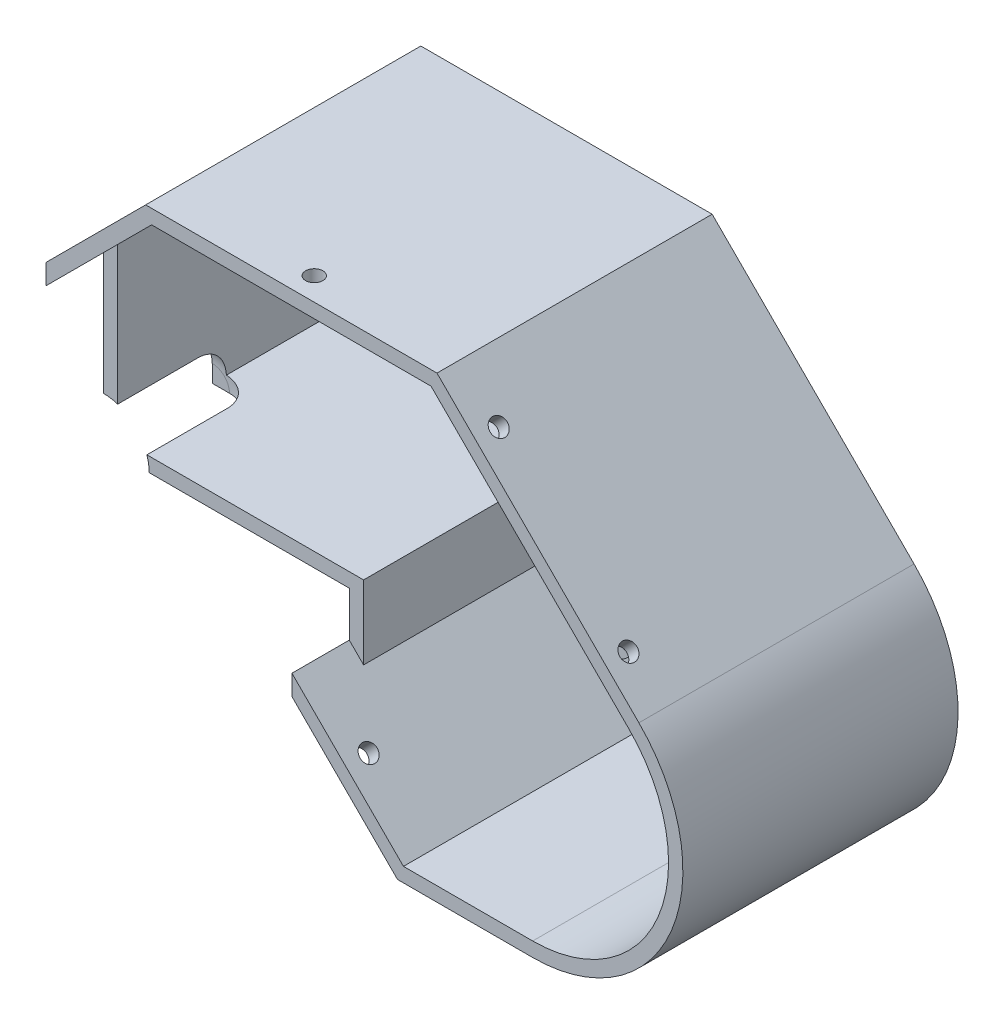
from build123d import *

# Parameters (mm, degrees)
RESSALTO_EXTRUS_O1_DEPTH = 48
ESBO_O12_R               = 1.5
CORTE_EXTRUS_O10_DEPTH   = 10
ESBO_O13_R               = 1.5
CORTE_EXTRUS_O11_DEPTH   = 10
ESBO_O14_R               = 1.5
CORTE_EXTRUS_O12_DEPTH   = 10
ESBO_O15_R               = 1.5
CORTE_EXTRUS_O13_DEPTH   = 10
CORTE_EXTRUS_O14_DEPTH   = 10
ESBO_O17_R               = 4
ESBO_O17_W               = 2.8
ESBO_O17_H               = 2.8
RESSALTO_EXTRUS_O2_DEPTH = 4
CORTE_EXTRUS_O15_DEPTH   = 10


with BuildPart() as part:
    # Model → Ressalto-extrusão1 (new body)
    with BuildSketch(Plane.XY):
        with BuildLine():
            Line((-0.7, 0), (39, 0))
            Line((39, 0), (39.7, 0))
            Line((39.7, 0), (39.7, -11.380317396))
            Line((39.7, -11.380317396), (50.182424304, -21.8627417))
            Line((50.182424304, -21.8627417), (58.119682605, -29.8))
            Line((58.119682605, -29.8), (81.7, -29.8))
            ThreePointArc((81.7, -29.8), (105.905643752, -13.626305928), (100.226197667, 14.926197667))
            Line((100.226197667, 14.926197667), (65.00338056, 50.149014774))
            Line((65.00338056, 50.149014774), (50.111140335, 50.149014774))
            Line((50.111140335, 50.149014774), (14.181595121, 50.149014774))
            Line((14.181595121, 50.149014774), (-3.2, 32.767419653))
            Line((-3.2, 32.767419653), (-3.2, 5))
            Line((-3.2, 5), (-3.2, 0))
            Line((-3.2, 0), (-0.7, 0))
        make_face()
        with BuildLine():
            Line((-0.7, 2.5), (39, 2.5))
            Line((39, 2.5), (39.7, 2.5))
            Line((39.7, 2.5), (42.2, 2.5))
            Line((42.2, 2.5), (42.2, -10.34478349))
            Line((42.2, -10.34478349), (51.950191257, -20.094974747))
            Line((51.950191257, -20.094974747), (59.15521651, -27.3))
            Line((59.15521651, -27.3), (81.7, -27.3))
            ThreePointArc((81.7, -27.3), (103.595944921, -12.669597347), (98.458430714, 13.158430714))
            Line((98.458430714, 13.158430714), (63.967846654, 47.649014774))
            Line((63.967846654, 47.649014774), (50.111140335, 47.649014774))
            Line((50.111140335, 47.649014774), (15.217129027, 47.649014774))
            Line((15.217129027, 47.649014774), (-0.7, 31.731885747))
            Line((-0.7, 31.731885747), (-0.7, 2.5))
        make_face(mode=Mode.SUBTRACT)
    extrude(amount=RESSALTO_EXTRUS_O1_DEPTH)

    # Esboço12 → Corte-extrusão10 (cut)
    with BuildSketch(Plane(origin=(57.576197667, 57.576197667, 0), x_dir=(0, 0, -1), z_dir=(0.707106781, 0.707106781, 0))):
        with Locations((-44, -20.072657306)):
            Circle(ESBO_O12_R)
        with Locations((-44, -52.072657306)):
            Circle(ESBO_O12_R)
    extrude(amount=-CORTE_EXTRUS_O10_DEPTH, mode=Mode.SUBTRACT)

    # Esboço13 → Corte-extrusão11 (cut)
    with BuildSketch(Plane(origin=(0, 50.149014774, 0), x_dir=(1, 0, 0), z_dir=(0, 1, 0))):
        with Locations((39.59248784, -44)):
            Circle(ESBO_O13_R)
    extrude(amount=-CORTE_EXTRUS_O11_DEPTH, mode=Mode.SUBTRACT)

    # Esboço14 → Corte-extrusão12 (cut)
    with BuildSketch(Plane.ZY.offset(3.2)):
        with Locations((44, 23.701037279)):
            Circle(ESBO_O14_R)
        with Locations((44, 7.740898975)):
            Circle(ESBO_O14_R)
    extrude(amount=-CORTE_EXTRUS_O12_DEPTH, mode=Mode.SUBTRACT)

    # Esboço15 → Corte-extrusão13 (cut)
    with BuildSketch(Plane(origin=(14.159841302, 14.159841302, 0), x_dir=(0, 0, 1), z_dir=(-0.707106781, -0.707106781, 0))):
        with Locations((44, -46.881179593)):
            Circle(ESBO_O15_R)
    extrude(amount=-CORTE_EXTRUS_O13_DEPTH, mode=Mode.SUBTRACT)

    # Esboço16 → Corte-extrusão14 (cut)
    with BuildSketch(Plane.XY.offset(48)):
        Polygon((39.7, 0), (39.7, -7.84478349), (42.2, -10.34478349), (42.2, 2.5), (-0.7, 2.5), (-0.7, 0), align=None)
    extrude(amount=-CORTE_EXTRUS_O14_DEPTH, mode=Mode.SUBTRACT)

    # Esboço17 → Ressalto-extrusão2 (add)
    with BuildSketch(Plane(origin=(0, 0, 0), x_dir=(-1, 0, 0), z_dir=(0, 0, -1))):
        with Locations((-91.568699638, 17.926841447)):
            Circle(ESBO_O17_R)
        with Locations((-91.568699638, 17.926841447)):
            Rectangle(ESBO_O17_W, ESBO_O17_H, mode=Mode.SUBTRACT)
        with Locations((-68.47265349, 41.022887595)):
            Circle(ESBO_O17_R)
        with Locations((-68.47265349, 41.022887595)):
            Rectangle(ESBO_O17_W, ESBO_O17_H, mode=Mode.SUBTRACT)
        with Locations((-39.59248784, 46.149014774)):
            Circle(ESBO_O17_R)
        with Locations((-39.59248784, 46.149014774)):
            Rectangle(ESBO_O17_W, ESBO_O17_H, mode=Mode.SUBTRACT)
        with Locations((-0.8, 24.383709827)):
            Circle(ESBO_O17_R)
        with Locations((-0.8, 24.383709827)):
            Rectangle(ESBO_O17_W, ESBO_O17_H, mode=Mode.SUBTRACT)
        with Locations((-0.8, 8.383709827)):
            Circle(ESBO_O17_R)
        with Locations((-0.8, 8.383709827)):
            Rectangle(ESBO_O17_W, ESBO_O17_H, mode=Mode.SUBTRACT)
        with Locations((-51.388268427, -17.411731573)):
            Circle(ESBO_O17_R)
        with Locations((-51.388268427, -17.411731573)):
            Rectangle(ESBO_O17_W, ESBO_O17_H, mode=Mode.SUBTRACT)
    extrude(amount=-RESSALTO_EXTRUS_O2_DEPTH)

    # Esboço18 → Corte-extrusão15 (cut)
    with BuildSketch(Plane.XY.offset(48)):
        Polygon((-0.7, 31.731885747), (-32.431885747, 0), (-0.7, 0), align=None)
    extrude(amount=-CORTE_EXTRUS_O15_DEPTH, mode=Mode.SUBTRACT)

    # Esboço19 → Corte-Revolução1 (revolve, cut)
    with BuildSketch(Plane.ZY.offset(3.2)):
        with BuildLine():
            Line((19, 0), (29, 0))
            Line((29, 0), (38.25689259, 0))
            Line((38.25689259, 0), (38.25689259, 8))
            Line((38.25689259, 8), (24, 8))
            ThreePointArc((24, 8), (20.464466094, 6.535533906), (19, 3))
            Line((19, 3), (19, 0))
        make_face()
    revolve(axis=Axis((-3.2, 0, 19), (0, 0, 1)), mode=Mode.SUBTRACT)


solid = part.part
